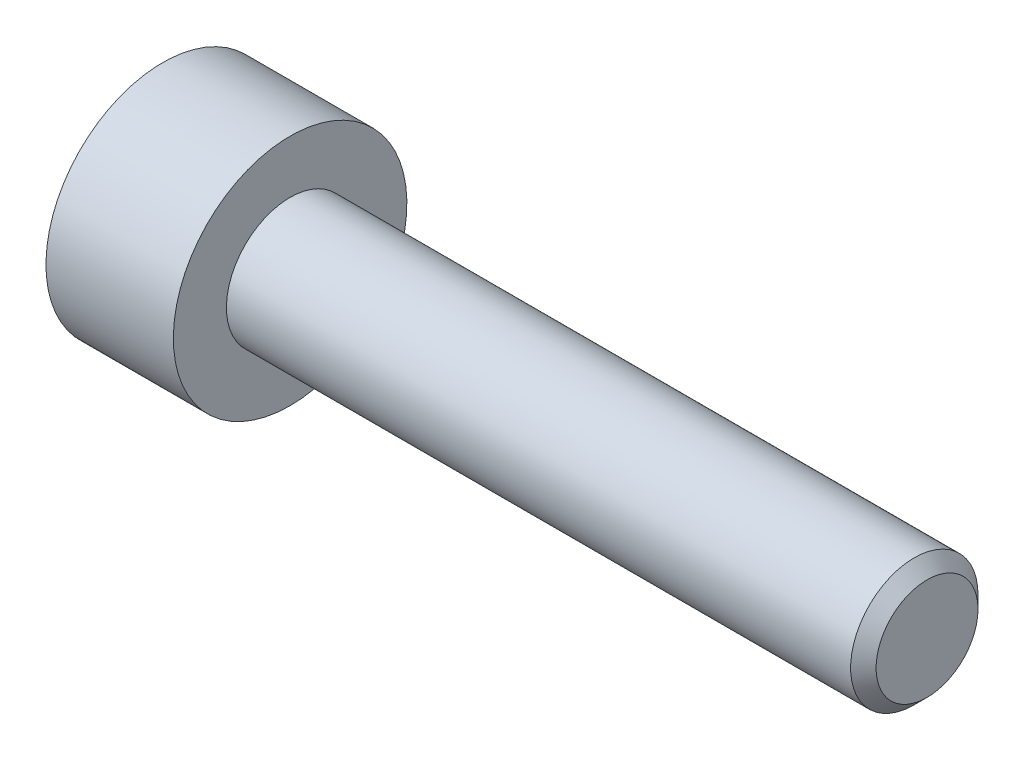
from build123d import *

# Parameters (mm, degrees)
SKETCH2_R           = 1.5
BOSS_EXTRUDE1_DEPTH = 15
CHAMFER1_SIZE       = 0.3
SKETCH6_W           = 3
SKETCH6_H           = 2.75
CUT_EXTRUDE1_DEPTH  = 1.6
SKETCH8_R           = 1.493375673
CUT_EXTRUDE2_DEPTH  = 1
CUT_EXTRUDE2_TAPER  = 45


with BuildPart() as part:
    # Sketch2 → Boss-Extrude1 (new body)
    with BuildSketch(Plane(origin=(0, 0, 0), x_dir=(0, 0, -1), z_dir=(1, 0, 0))):
        Circle(SKETCH2_R)
    extrude(amount=-BOSS_EXTRUDE1_DEPTH)

    # Chamfer1
    chamfer1_edges = [part.edges().sort_by_distance(p)[0] for p in [
        (0, 0, 1.5),
    ]]
    chamfer(chamfer1_edges, length=CHAMFER1_SIZE)

    # Sketch6 → Revolve1 (revolve)
    with BuildSketch(Plane.XY):
        with Locations((-16.5, 1.375)):
            Rectangle(SKETCH6_W, SKETCH6_H)
    revolve(axis=Axis((-15, 0, 0), (1, 0, 0)))

    # Sketch7 → Cut-Extrude1 (cut)
    with BuildSketch(Plane.ZY.offset(18)):
        Polygon((0, 1.443375673), (-1.25, 0.721687836), (-1.25, -0.721687836), (0, -1.443375673), (1.25, -0.721687836), (1.25, 0.721687836), align=None)
    extrude(amount=-CUT_EXTRUDE1_DEPTH, mode=Mode.SUBTRACT)

    # Sketch8 → Cut-Extrude2 (cut)
    with BuildSketch(Plane.ZY.offset(18)):
        Circle(SKETCH8_R)
    extrude(amount=-CUT_EXTRUDE2_DEPTH, taper=CUT_EXTRUDE2_TAPER, mode=Mode.SUBTRACT)


solid = part.part
